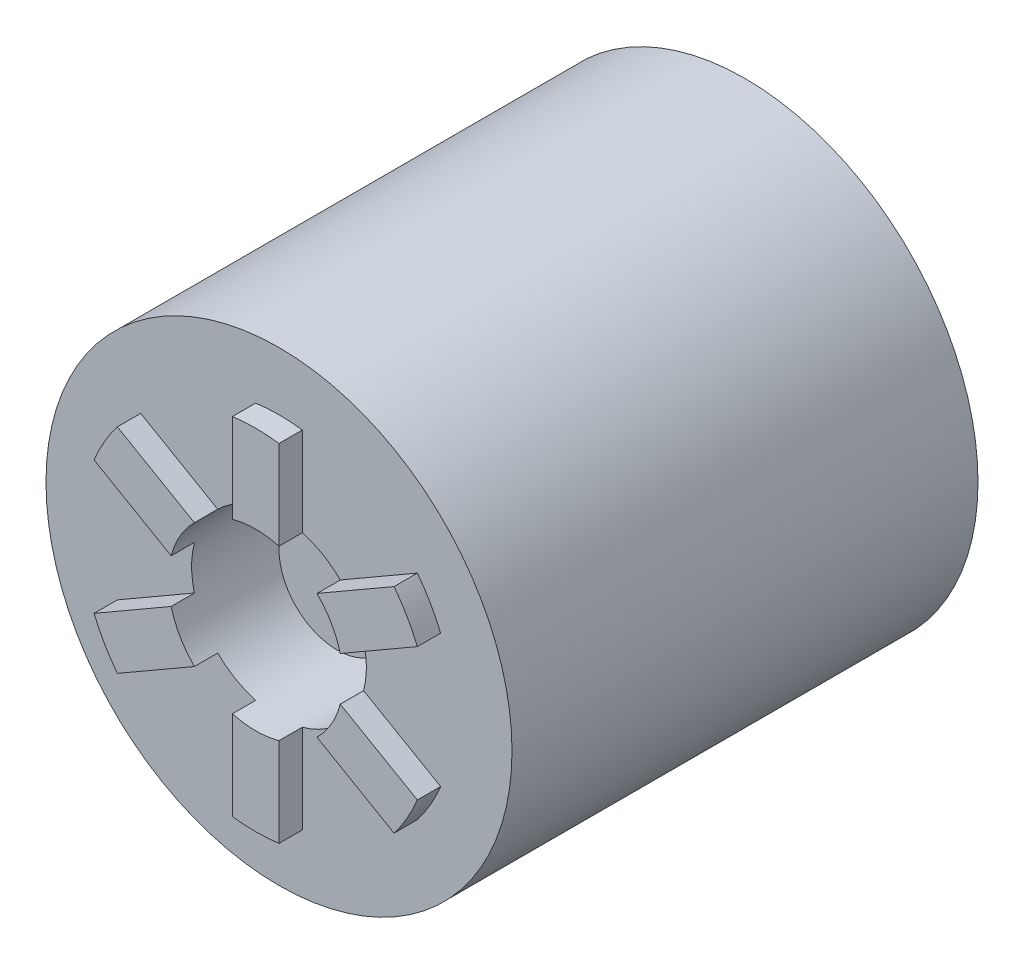
from build123d import *

# Parameters (mm, degrees)
SKETCH5_R           = 20
BOSS_EXTRUDE3_DEPTH = 40
SKETCH6_R           = 7.5
CUT_EXTRUDE3_DEPTH  = 10
BOSS_EXTRUDE4_DEPTH = 2
SKETCH8_R           = 5
CUT_EXTRUDE6_DEPTH  = 25
SKETCH9_R           = 12.5
CUT_EXTRUDE7_DEPTH  = 5
SKETCH10_R          = 5
BOSS_EXTRUDE5_DEPTH = 5


with BuildPart() as part:
    # Sketch5 → Boss-Extrude3 (new body)
    with BuildSketch(Plane.XY):
        Circle(SKETCH5_R)
    extrude(amount=BOSS_EXTRUDE3_DEPTH)

    # Sketch6 → Cut-Extrude3 (cut)
    with BuildSketch(Plane.XY.offset(40)):
        Circle(SKETCH6_R)
    extrude(amount=-CUT_EXTRUDE3_DEPTH, mode=Mode.SUBTRACT)

    # Sketch7 → Boss-Extrude4 (add)
    with BuildSketch(Plane.XY.offset(40)):
        with BuildLine():
            ThreePointArc((-2, 7.228416147), (0, 7.5), (2, 7.228416147))
            Line((2, 7.228416147), (2, 14.866068747))
            ThreePointArc((2, 14.866068747), (0, 15), (-2, 14.866068747))
            Line((-2, 14.866068747), (-2, 7.228416147))
        make_face()
        with BuildLine():
            Line((11.87439319, 9.165085181), (5.259992013, 5.346258881))
            ThreePointArc((5.259992013, 5.346258881), (6.495190528, 3.75), (7.259992013, 1.882157266))
            Line((7.259992013, 1.882157266), (13.87439319, 5.700983566))
            ThreePointArc((13.87439319, 5.700983566), (12.990381057, 7.5), (11.87439319, 9.165085181))
        make_face()
        with BuildLine():
            Line((13.87439319, -5.700983566), (7.259992013, -1.882157266))
            ThreePointArc((7.259992013, -1.882157266), (6.495190528, -3.75), (5.259992013, -5.346258881))
            Line((5.259992013, -5.346258881), (11.87439319, -9.165085181))
            ThreePointArc((11.87439319, -9.165085181), (12.990381057, -7.5), (13.87439319, -5.700983566))
        make_face()
        with BuildLine():
            Line((2, -14.866068747), (2, -7.228416147))
            ThreePointArc((2, -7.228416147), (0, -7.5), (-2, -7.228416147))
            Line((-2, -7.228416147), (-2, -14.866068747))
            ThreePointArc((-2, -14.866068747), (0, -15), (2, -14.866068747))
        make_face()
        with BuildLine():
            ThreePointArc((-5.259992013, -5.346258881), (-6.495190528, -3.75), (-7.259992013, -1.882157266))
            Line((-7.259992013, -1.882157266), (-13.87439319, -5.700983566))
            ThreePointArc((-13.87439319, -5.700983566), (-12.990381057, -7.5), (-11.87439319, -9.165085181))
            Line((-11.87439319, -9.165085181), (-5.259992013, -5.346258881))
        make_face()
        with BuildLine():
            ThreePointArc((-7.259992013, 1.882157266), (-6.495190528, 3.75), (-5.259992013, 5.346258881))
            Line((-5.259992013, 5.346258881), (-11.87439319, 9.165085181))
            ThreePointArc((-11.87439319, 9.165085181), (-12.990381057, 7.5), (-13.87439319, 5.700983566))
            Line((-13.87439319, 5.700983566), (-7.259992013, 1.882157266))
        make_face()
    extrude(amount=BOSS_EXTRUDE4_DEPTH)

    # Sketch8 → Cut-Extrude6 (cut)
    with BuildSketch(Plane(origin=(0, 0, 0), x_dir=(-1, 0, 0), z_dir=(0, 0, -1))):
        Circle(SKETCH8_R)
    extrude(amount=-CUT_EXTRUDE6_DEPTH, mode=Mode.SUBTRACT)

    # Sketch9 → Cut-Extrude7 (cut)
    with BuildSketch(Plane(origin=(0, 0, 0), x_dir=(-1, 0, 0), z_dir=(0, 0, -1))):
        Circle(SKETCH9_R)
    extrude(amount=-CUT_EXTRUDE7_DEPTH, mode=Mode.SUBTRACT)

    # Sketch10 → Boss-Extrude5 (add)
    with BuildSketch(Plane.XY.offset(30)):
        Circle(SKETCH10_R)
    extrude(amount=BOSS_EXTRUDE5_DEPTH)


solid = part.part
